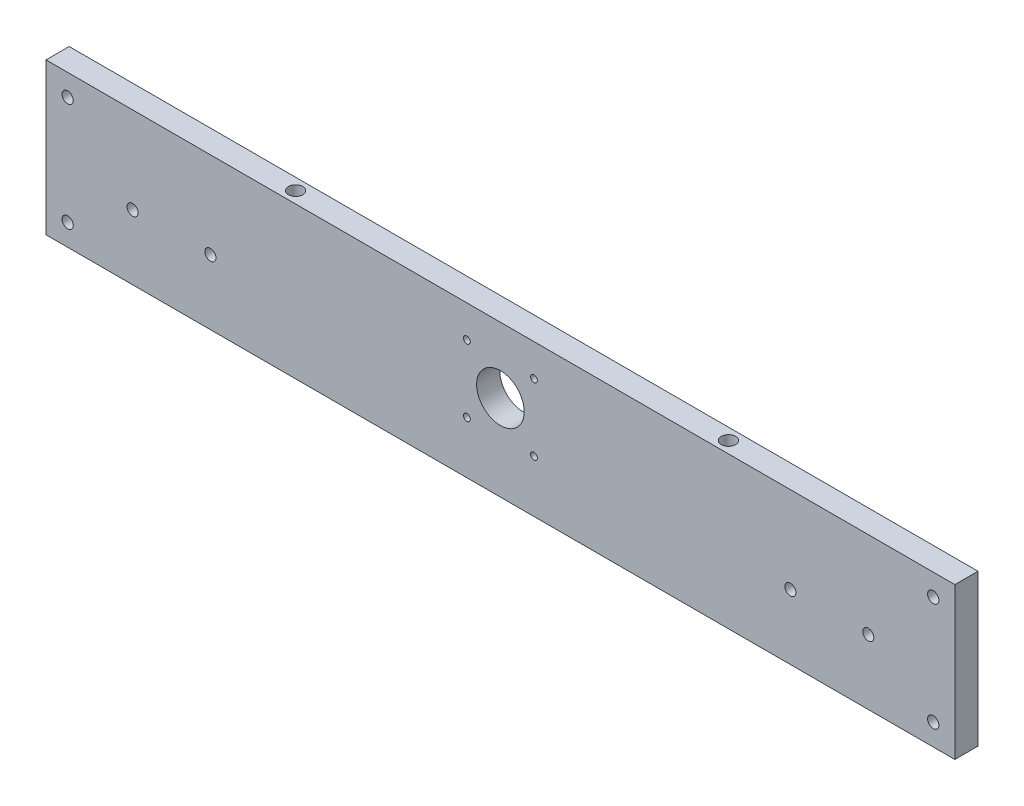
from build123d import *

# Parameters (mm, degrees)
ESBO_O1_W                                   = 420
ESBO_O1_H                                   = 70
RESSALTO_EXTRUS_O1_DEPTH                    = 10.7
ESBO_O4_R                                   = 11
CORTE_EXTRUS_O3_DEPTH                       = 11.7
FURO_ROSCADO_PARA_CONDU_TE_DE_10_321_D      = 5.1054
FURO_ROSCADO_PARA_CONDU_TE_DE_M5X0_81_D     = 5.2
FURO_ROSCADO_PARA_CONDU_TE_DE_M3X0_51_D     = 3.15
FURO_ROSCADO_PARA_CONDU_TE_DE_1_4_281_D     = 6.6294
FURO_ROSCADO_PARA_CONDU_TE_DE_1_4_281_DEPTH = 15
FURO_ROSCADO_PARA_CONDU_TE_DE_1_4_281_TIP   = 1.991672694


with BuildPart() as part:
    # Esboço1 → Ressalto-extrusão1 (new body)
    with BuildSketch(Plane.XY):
        Rectangle(ESBO_O1_W, ESBO_O1_H)
    extrude(amount=RESSALTO_EXTRUS_O1_DEPTH)

    # Esboço4 → Corte-extrusão3 (cut, through all)
    with BuildSketch(Plane.XY.offset(10.7)):
        with Locations((0, 4.65)):
            Circle(ESBO_O4_R)
    extrude(amount=-CORTE_EXTRUS_O3_DEPTH, mode=Mode.SUBTRACT)

    # Furo roscado para conduíte de #10-321 (through all)
    with Locations(Plane.XY.offset(10.7)):
        with Locations((-170, -5), (-134, -5), (134, -5), (170, -5)):
            Hole(FURO_ROSCADO_PARA_CONDU_TE_DE_10_321_D / 2)

    # Furo roscado para conduíte de M5x0.81 (through all)
    with Locations(Plane.XY.offset(10.7)):
        with Locations((-200, 25), (-200, -25), (200, -25), (200, 25)):
            Hole(FURO_ROSCADO_PARA_CONDU_TE_DE_M5X0_81_D / 2)

    # Furo roscado para conduíte de M3x0.51 (through all)
    with Locations(Plane.XY.offset(10.7)):
        with Locations((-15.5, 20.15), (-15.5, -10.85), (15.5, -10.85), (15.5, 20.15)):
            Hole(FURO_ROSCADO_PARA_CONDU_TE_DE_M3X0_51_D / 2)

    # Furo roscado para conduíte de 1/4-281
    with Locations(Plane(origin=(0, 35, 0), x_dir=(1, 0, 0), z_dir=(0, 1, 0))):
        with Locations((-100, -5.35), (100, -5.35)):
            Hole(FURO_ROSCADO_PARA_CONDU_TE_DE_1_4_281_D / 2, depth=FURO_ROSCADO_PARA_CONDU_TE_DE_1_4_281_DEPTH)
            with Locations((0, 0, -(FURO_ROSCADO_PARA_CONDU_TE_DE_1_4_281_DEPTH + FURO_ROSCADO_PARA_CONDU_TE_DE_1_4_281_TIP / 2))):  # 118° drill point
                Cone(0, FURO_ROSCADO_PARA_CONDU_TE_DE_1_4_281_D / 2, FURO_ROSCADO_PARA_CONDU_TE_DE_1_4_281_TIP, mode=Mode.SUBTRACT)


solid = part.part
